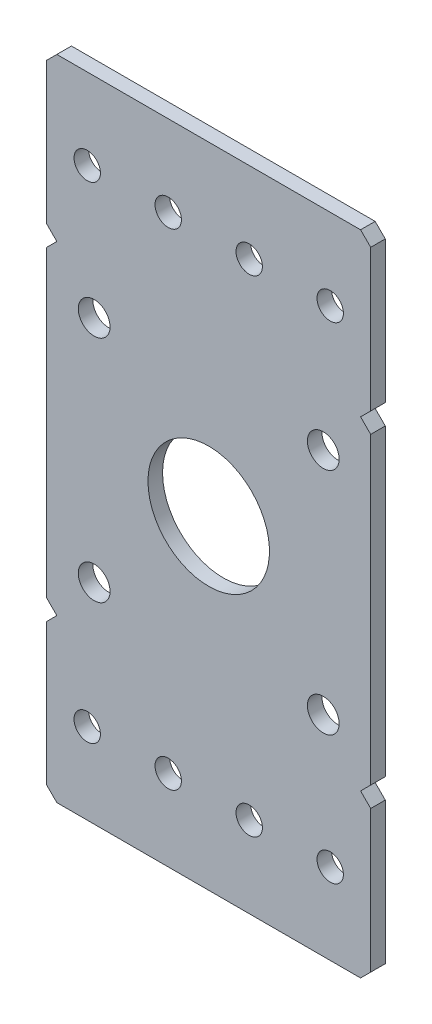
from build123d import *

# Parameters (mm, degrees)
SKETCH1_R           = 2.4892
SKETCH1_R_2         = 2.0701
SKETCH1_R_3         = 9.525
BOSS_EXTRUDE1_DEPTH = 2.286


with BuildPart() as part:
    # Sketch1 → Boss-Extrude1 (new body)
    with BuildSketch(Plane.XY.offset(2.286)):
        Polygon((25.4, -26.9875), (23.8125, -25.4), (25.4, -23.8125), (25.4, 23.8125), (23.8125, 25.4), (25.4, 26.9875), (25.4, 49.2125), (23.8125, 50.8), (-23.8125, 50.8), (-25.4, 49.2125), (-25.4, 26.9875), (-23.8125, 25.4), (-25.4, 23.8125), (-25.4, -23.8125), (-23.8125, -25.4), (-25.4, -26.9875), (-25.4, -49.2125), (-23.8125, -50.8), (23.8125, -50.8), (25.4, -49.2125), align=None)
        with Locations((-17.960512242, -17.960512242)):
            Circle(SKETCH1_R, mode=Mode.SUBTRACT)
        with Locations((-19.05, -38.1)):
            Circle(SKETCH1_R_2, mode=Mode.SUBTRACT)
        with Locations((-6.35, -38.1)):
            Circle(SKETCH1_R_2, mode=Mode.SUBTRACT)
        with Locations((19.05, -38.1)):
            Circle(SKETCH1_R_2, mode=Mode.SUBTRACT)
        Circle(SKETCH1_R_3, mode=Mode.SUBTRACT)
        with Locations((6.35, 38.1)):
            Circle(SKETCH1_R_2, mode=Mode.SUBTRACT)
        with Locations((-19.05, 38.1)):
            Circle(SKETCH1_R_2, mode=Mode.SUBTRACT)
        with Locations((-6.35, 38.1)):
            Circle(SKETCH1_R_2, mode=Mode.SUBTRACT)
        with Locations((19.05, 38.1)):
            Circle(SKETCH1_R_2, mode=Mode.SUBTRACT)
        with Locations((-17.960512242, 17.960512242)):
            Circle(SKETCH1_R, mode=Mode.SUBTRACT)
        with Locations((6.35, -38.1)):
            Circle(SKETCH1_R_2, mode=Mode.SUBTRACT)
        with Locations((17.960512242, -17.960512242)):
            Circle(SKETCH1_R, mode=Mode.SUBTRACT)
        with Locations((17.960512242, 17.960512242)):
            Circle(SKETCH1_R, mode=Mode.SUBTRACT)
    extrude(amount=-BOSS_EXTRUDE1_DEPTH)


solid = part.part
